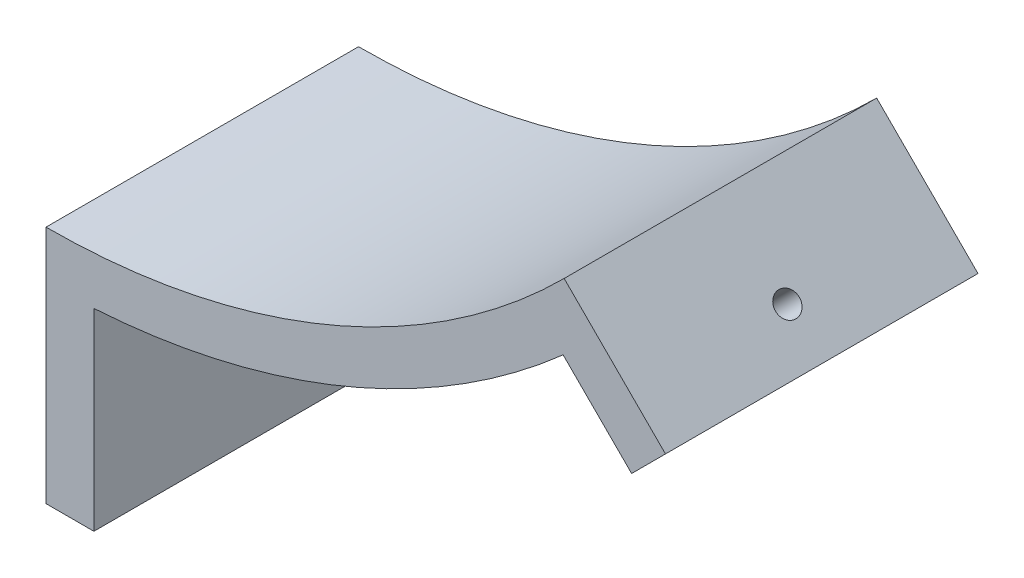
from build123d import *

# Parameters (mm, degrees)
SALIENTE_EXTRUIR1_DEPTH = 65.25
CROQUIS5_R              = 2.5
CORTAR_EXTRUIR3_DEPTH   = 45
CROQUIS6_R              = 2.5
CORTAR_EXTRUIR4_DEPTH   = 12


with BuildPart() as part:
    # Croquis1 → Saliente-Extruir1 (new body)
    with BuildSketch(Plane.XY):
        with BuildLine():
            Line((129.342755363, -129.342755363), (108.187337522, -108.187337522))
            ThreePointArc((108.187337522, -108.187337522), (58.550565152, -141.353568474), (0, -153))
            Line((0, -153), (0, -163))
            Line((0, -163), (0, -203))
            Line((0, -203), (10, -203))
            Line((10, -203), (10, -162.692962355))
            ThreePointArc((10, -162.692962355), (62.377399476, -150.592363799), (107.970229121, -122.112364745))
            Line((107.970229121, -122.112364745), (122.271687551, -136.413823175))
            Line((122.271687551, -136.413823175), (129.342755363, -129.342755363))
        make_face()
    extrude(amount=SALIENTE_EXTRUIR1_DEPTH)

    # Croquis5 → Cortar-Extruir3 (cut)
    with BuildSketch(Plane(origin=(10, 0, 0), x_dir=(0, 0, -1), z_dir=(1, 0, 0))):
        with Locations((-32.625, -183)):
            Circle(CROQUIS5_R)
    extrude(amount=-CORTAR_EXTRUIR3_DEPTH, mode=Mode.SUBTRACT)

    # Croquis6 → Cortar-Extruir4 (cut)
    with BuildSketch(Plane(origin=(0, 0, 0), x_dir=(0, 0, -1), z_dir=(0.707106781, 0.707106781, 0))):
        with Locations((-32.62, -172.768278829)):
            Circle(CROQUIS6_R)
    extrude(amount=-CORTAR_EXTRUIR4_DEPTH, mode=Mode.SUBTRACT)


solid = part.part
